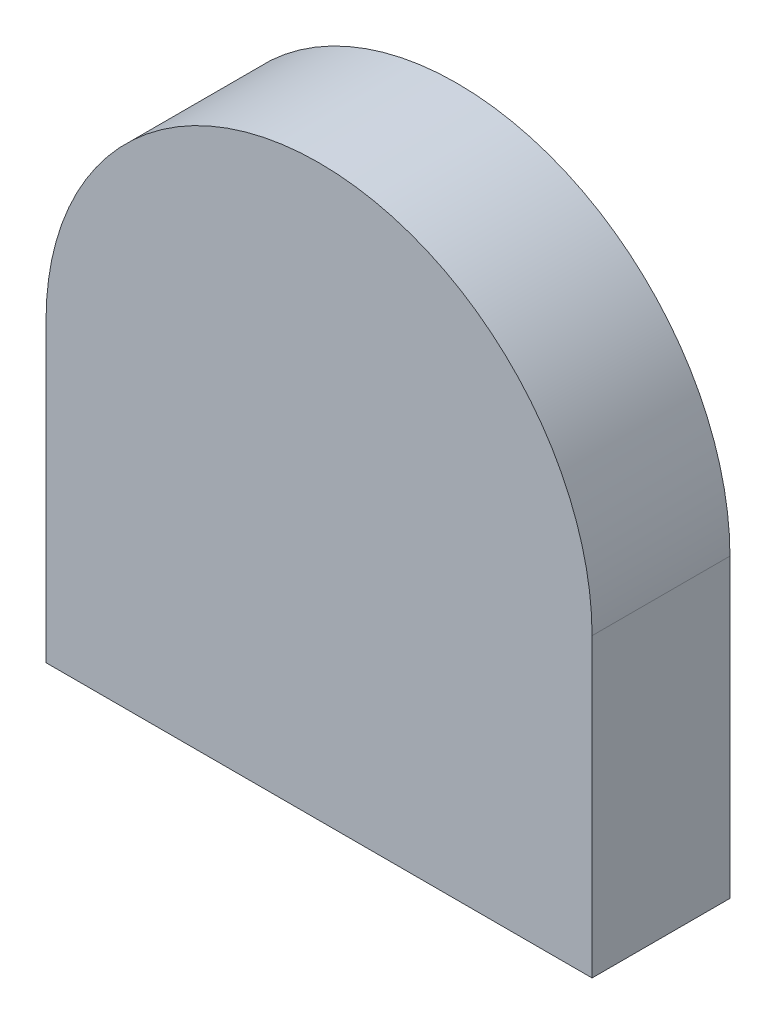
from build123d import *

# Parameters (mm, degrees)
DODANIE_WYCI_GNI_CIE1_DEPTH = 10


with BuildPart() as part:
    # Szkic1 → Dodanie-wyciągnięcie1 (new body)
    with BuildSketch(Plane.XY):
        with BuildLine():
            Line((0, 0), (39.6, 0))
            Line((39.6, 0), (39.6, 21.5))
            ThreePointArc((39.6, 21.5), (19.8, 41.3), (0, 21.5))
            Line((0, 21.5), (0, 0))
        make_face()
    extrude(amount=DODANIE_WYCI_GNI_CIE1_DEPTH)


solid = part.part
